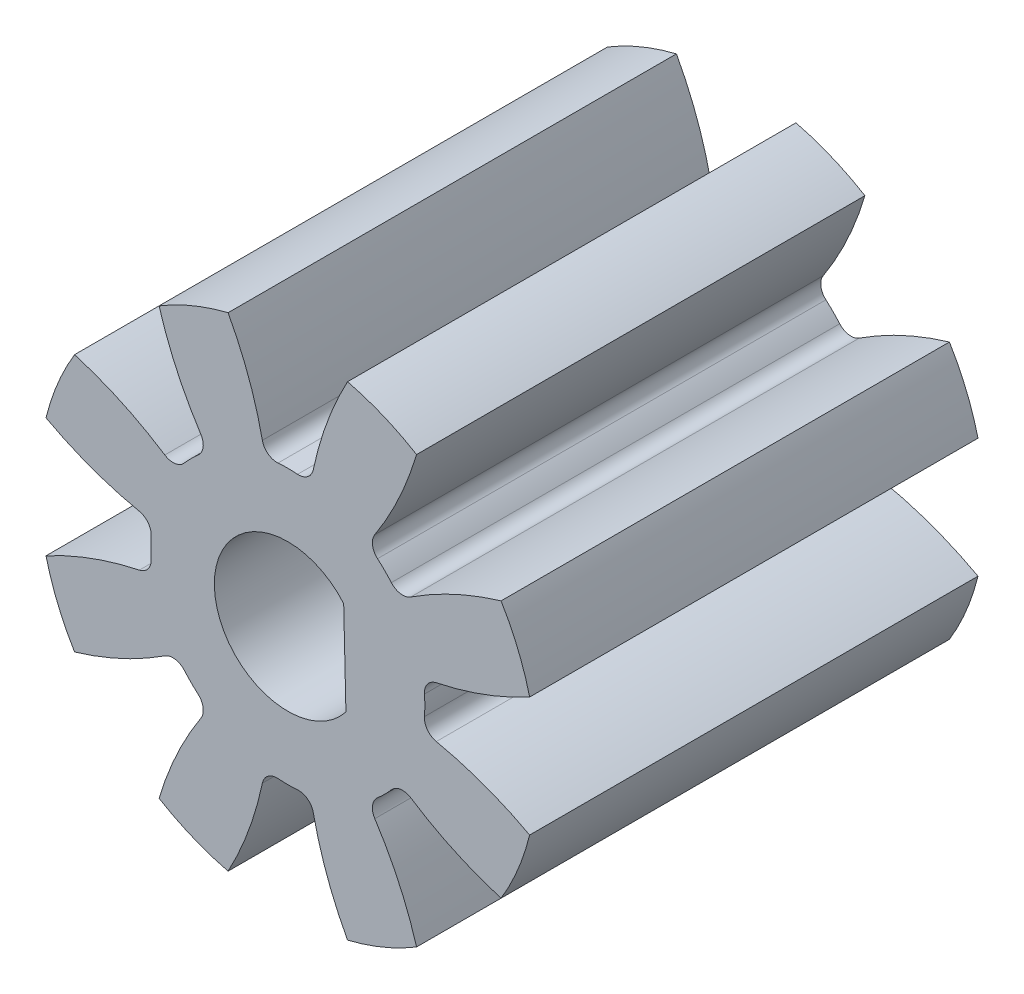
from build123d import *

# Parameters (mm, degrees)
CROQUIS1_R              = 10
SALIENTE_EXTRUIR1_DEPTH = 9
CORTAR_EXTRUIR1_DEPTH   = 10
REDONDEO1_R             = 0.6
MATRIZC1_COUNT          = 8
REDONDEO1_OF_MATRIZC1_R = 0.6
CORTAR_EXTRUIR2_START   = 9
CORTAR_EXTRUIR2_DEPTH   = 18


with BuildPart() as part:
    # Croquis1 → Saliente-Extruir1 (new body, symmetric)
    with BuildSketch(Plane.XY):
        Circle(CROQUIS1_R)
    extrude(amount=SALIENTE_EXTRUIR1_DEPTH, both=True)

    # Croquis2 → Cortar-Extruir1 (cut, symmetric)
    with BuildSketch(Plane.XY):
        with BuildLine():
            ThreePointArc((-0.919743931, 5.422552084), (-1.661499877, 8.114509659), (-2.927549332, 10.603275669))
            ThreePointArc((-2.927549332, 10.603275669), (0, 11), (2.927549332, 10.603275669))
            ThreePointArc((2.927549332, 10.603275669), (1.661499877, 8.114509659), (0.919743931, 5.422552084))
            ThreePointArc((0.919743931, 5.422552084), (0, 5.5), (-0.919743931, 5.422552084))
        make_face()
    cortar_extruir1 = extrude(amount=CORTAR_EXTRUIR1_DEPTH, both=True, mode=Mode.SUBTRACT)

    # Redondeo1
    redondeo1_edges = [part.edges().sort_by_distance(p)[0] for p in [
        (-0.919743931, 5.422552084, 0),
        (0.919743931, 5.422552084, 0),
    ]]
    fillet(redondeo1_edges, radius=REDONDEO1_R)

    # MatrizC1: Cortar-Extruir1 ×8 about axis
    matrizc1_axis = Axis((0, 0, 0), (0, 0, 1))
    for i in range(1, MATRIZC1_COUNT):
        add(cortar_extruir1.rotate(matrizc1_axis, i * 360 / MATRIZC1_COUNT), mode=Mode.SUBTRACT)

    # Redondeo1 of MatrizC1
    redondeo1_of_matrizc1_edges = [part.edges().sort_by_distance(p)[0] for p in [
        (-4.48468052, 3.183966179, 0),
        (-3.183966179, 4.48468052, 0),
        (-5.422552084, -0.919743931, 0),
        (-5.422552084, 0.919743931, 0),
        (-3.183966179, -4.48468052, 0),
        (-4.48468052, -3.183966179, 0),
        (0.919743931, -5.422552084, 0),
        (-0.919743931, -5.422552084, 0),
        (4.48468052, -3.183966179, 0),
        (3.183966179, -4.48468052, 0),
        (5.422552084, 0.919743931, 0),
        (5.422552084, -0.919743931, 0),
        (3.183966179, 4.48468052, 0),
        (4.48468052, 3.183966179, 0),
    ]]
    fillet(redondeo1_of_matrizc1_edges, radius=REDONDEO1_OF_MATRIZC1_R)

    # Croquis3 → Cortar-Extruir2 (cut)
    with BuildSketch(Plane.XY.offset(CORTAR_EXTRUIR2_START)):
        with BuildLine():
            Line((2.242939686, 1.916173678), (2.332740976, -1.805773944))
            ThreePointArc((2.332740976, -1.805773944), (-2.949141724, -0.071155416), (2.242939686, 1.916173678))
        make_face()
    extrude(amount=-CORTAR_EXTRUIR2_DEPTH, mode=Mode.SUBTRACT)


solid = part.part
